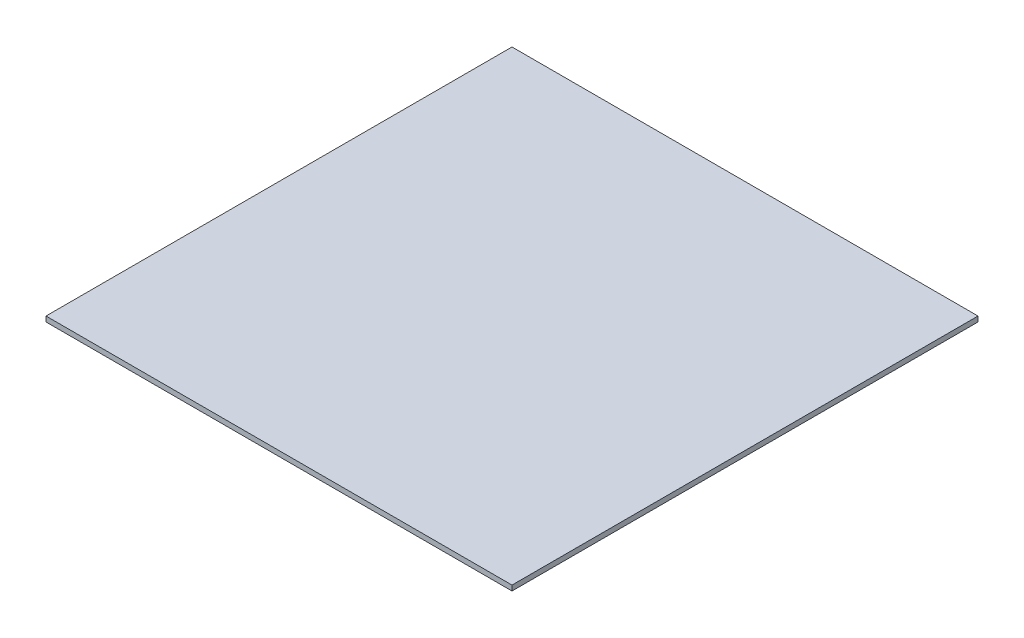
from build123d import *

# Parameters (mm, degrees)
SKETCH_1_W      = 270
SKETCH_1_H      = 270
EXTRUDE_1_DEPTH = 3


with BuildPart() as part:
    # 草图1 → 凸台-拉伸1 (new body)
    with BuildSketch(Plane(origin=(0, 0, 0), x_dir=(1, 0, 0), z_dir=(0, 1, 0))):
        Rectangle(SKETCH_1_W, SKETCH_1_H)
    extrude(amount=EXTRUDE_1_DEPTH)


solid = part.part
